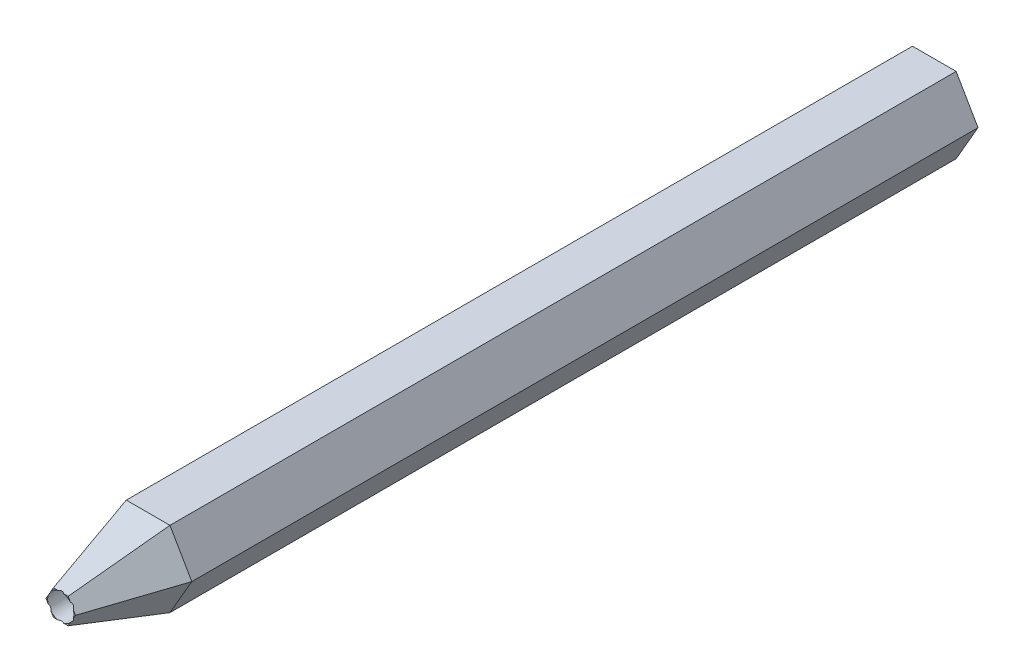
from build123d import *
from OCP.BRepFilletAPI import BRepFilletAPI_MakeChamfer

# Parameters (mm, degrees)
VYSUNOUT1_DEPTH          = 100
ZKOSIT2_SIZE             = 10
ZKOSIT2_SIZE2            = 2.867453858
SKICA2_R                 = 1.5
ODEBRAT_VYSUNUT_M1_DEPTH = 101.218511264


with BuildPart() as part:
    # Skica1 → Vysunout1 (new body)
    with BuildSketch(Plane.XY):
        Polygon((2.5, -4.330127019), (5, 0), (2.5, 4.330127019), (-2.5, 4.330127019), (-5, 0), (-2.5, -4.330127019), align=None)
    extrude(amount=VYSUNOUT1_DEPTH)

    # Zkosit2: one chamfer whose edges measure the first distance from different faces: ONE call of the kernel's chamfer builder (chamfer() names one face for all edges)
    zkosit2_edges_1 = [part.edges().sort_by_distance(p)[0] for p in [
        (3.75, 2.165063509, 100),
    ]]
    zkosit2_side_1 = [part.faces().sort_by_distance(p)[0] for p in [
        (3.75, 2.165063509, 50),
    ]]
    zkosit2_edges_2 = [part.edges().sort_by_distance(p)[0] for p in [
        (0, 4.330127019, 100),
    ]]
    zkosit2_side_2 = [part.faces().sort_by_distance(p)[0] for p in [
        (0, 4.330127019, 50),
    ]]
    zkosit2_edges_3 = [part.edges().sort_by_distance(p)[0] for p in [
        (-3.75, 2.165063509, 100),
    ]]
    zkosit2_side_3 = [part.faces().sort_by_distance(p)[0] for p in [
        (-3.75, 2.165063509, 50),
    ]]
    zkosit2_edges_4 = [part.edges().sort_by_distance(p)[0] for p in [
        (-3.75, -2.165063509, 100),
    ]]
    zkosit2_side_4 = [part.faces().sort_by_distance(p)[0] for p in [
        (-3.75, -2.165063509, 50),
    ]]
    zkosit2_edges_5 = [part.edges().sort_by_distance(p)[0] for p in [
        (0, -4.330127019, 100),
    ]]
    zkosit2_side_5 = [part.faces().sort_by_distance(p)[0] for p in [
        (0, -4.330127019, 50),
    ]]
    zkosit2_edges_6 = [part.edges().sort_by_distance(p)[0] for p in [
        (3.75, -2.165063509, 100),
    ]]
    zkosit2_side_6 = [part.faces().sort_by_distance(p)[0] for p in [
        (3.75, -2.165063509, 50),
    ]]
    zkosit2 = BRepFilletAPI_MakeChamfer(part.part.solid().wrapped)
    for e in zkosit2_edges_1:
        zkosit2.Add(ZKOSIT2_SIZE, ZKOSIT2_SIZE2, e.wrapped, zkosit2_side_1[0].wrapped)  # the first distance lies on this face
    for e in zkosit2_edges_2:
        zkosit2.Add(ZKOSIT2_SIZE, ZKOSIT2_SIZE2, e.wrapped, zkosit2_side_2[0].wrapped)  # the first distance lies on this face
    for e in zkosit2_edges_3:
        zkosit2.Add(ZKOSIT2_SIZE, ZKOSIT2_SIZE2, e.wrapped, zkosit2_side_3[0].wrapped)  # the first distance lies on this face
    for e in zkosit2_edges_4:
        zkosit2.Add(ZKOSIT2_SIZE, ZKOSIT2_SIZE2, e.wrapped, zkosit2_side_4[0].wrapped)  # the first distance lies on this face
    for e in zkosit2_edges_5:
        zkosit2.Add(ZKOSIT2_SIZE, ZKOSIT2_SIZE2, e.wrapped, zkosit2_side_5[0].wrapped)  # the first distance lies on this face
    for e in zkosit2_edges_6:
        zkosit2.Add(ZKOSIT2_SIZE, ZKOSIT2_SIZE2, e.wrapped, zkosit2_side_6[0].wrapped)  # the first distance lies on this face
    add(Compound.cast(zkosit2.Shape()), mode=Mode.REPLACE)

    # Skica2 → Odebrat vysunutím1 (cut, through all)
    with BuildSketch(Plane.XY.offset(100)):
        Circle(SKICA2_R)
    extrude(amount=-ODEBRAT_VYSUNUT_M1_DEPTH, mode=Mode.SUBTRACT)


solid = part.part
